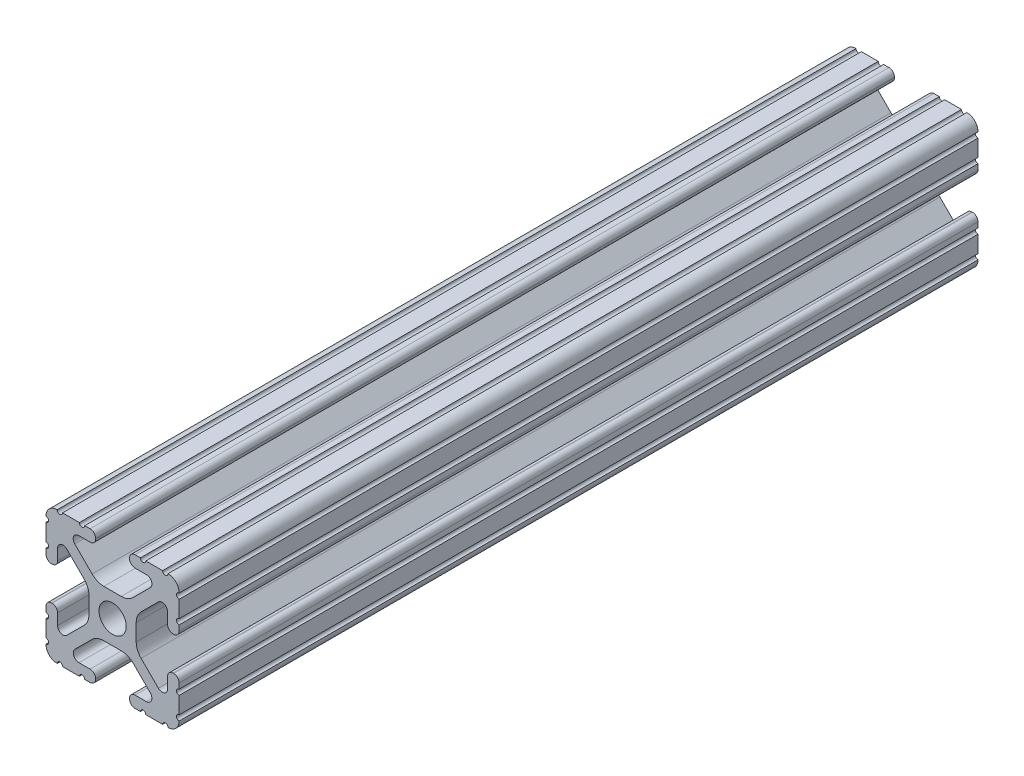
from build123d import *

# Parameters (mm, degrees)
SKETCH1_R           = 2.6035
BOSS_EXTRUDE1_DEPTH = 304.8
SKETCH2_R           = 37.713648337
CUT_EXTRUDE1_DEPTH  = 203.2
SKETCH4_R           = 34.529117014
CUT_EXTRUDE3_DEPTH  = 254
SKETCH5_R           = 0.254
CUT_EXTRUDE4_DEPTH  = 254


with BuildPart() as part:
    # Sketch1 → Boss-Extrude1 (new, symmetric)
    with BuildSketch(Plane.XY):
        with BuildLine():
            Line((-7.179650497, -8.645192506), (-3.952270251, -5.423690499))
            ThreePointArc((-3.952270251, -5.423690499), (-2.922936451, -4.736929036), (-1.709253557, -4.4958))
            Line((-1.709253557, -4.4958), (1.709253557, -4.4958))
            ThreePointArc((1.709253557, -4.4958), (2.922936451, -4.736929036), (3.952270251, -5.423690499))
            Line((3.952270251, -5.423690499), (7.179650497, -8.645192506))
            ThreePointArc((7.179650497, -8.645192506), (7.41473083, -9.822813117), (6.416408329, -10.4902))
            Line((6.416408329, -10.4902), (4.287512407, -10.4902))
            ThreePointArc((4.287512407, -10.4902), (3.54574862, -10.79744862), (3.2385, -11.539212407))
            Line((3.2385, -11.539212407), (3.2385, -11.650987593))
            ThreePointArc((3.2385, -11.650987593), (3.54574862, -12.39275138), (4.287512407, -12.7))
            Line((4.287512407, -12.7), (5.317126718, -12.7))
            ThreePointArc((5.317126718, -12.7), (5.825126718, -12.192), (6.333126718, -12.7))
            Line((6.333126718, -12.7), (9.550443118, -12.7))
            ThreePointArc((9.550443118, -12.7), (10.058366869, -12.192000006), (10.566443095, -12.699847501))
            ThreePointArc((10.566443095, -12.699847501), (12.082537762, -12.08250727), (12.699846982, -10.566399977))
            ThreePointArc((12.699846982, -10.566399977), (12.192000006, -10.058323491), (12.7, -9.5504))
            Line((12.7, -9.5504), (12.7, -6.3330836))
            ThreePointArc((12.7, -6.3330836), (12.192, -5.8250836), (12.7, -5.3170836))
            Line((12.7, -5.3170836), (12.7, -4.287469289))
            ThreePointArc((12.7, -4.287469289), (12.39275138, -3.545705502), (11.650987593, -3.238456882))
            Line((11.650987593, -3.238456882), (11.539212407, -3.238456882))
            ThreePointArc((11.539212407, -3.238456882), (10.79744862, -3.545705502), (10.4902, -4.287469289))
            Line((10.4902, -4.287469289), (10.4902, -6.402089023))
            ThreePointArc((10.4902, -6.402089023), (9.856505071, -7.351067942), (8.737131347, -7.129408934))
            Line((8.737131347, -7.129408934), (5.441005833, -3.840816462))
            ThreePointArc((5.441005833, -3.840816462), (4.750877967, -2.809883091), (4.5085, -1.593185507))
            Line((4.5085, -1.593185507), (4.5085, 1.593185507))
            ThreePointArc((4.5085, 1.593185507), (4.750877967, 2.809883091), (5.441005833, 3.840816462))
            Line((5.441005833, 3.840816462), (8.737131347, 7.129408934))
            ThreePointArc((8.737131347, 7.129408934), (9.856505071, 7.351067942), (10.4902, 6.402089023))
            Line((10.4902, 6.402089023), (10.4902, 4.287469289))
            ThreePointArc((10.4902, 4.287469289), (10.79744862, 3.545705502), (11.539212407, 3.238456882))
            Line((11.539212407, 3.238456882), (11.650987593, 3.238456882))
            ThreePointArc((11.650987593, 3.238456882), (12.39275138, 3.545705502), (12.7, 4.287469289))
            Line((12.7, 4.287469289), (12.7, 5.3170836))
            ThreePointArc((12.7, 5.3170836), (12.192, 5.8250836), (12.7, 6.3330836))
            Line((12.7, 6.3330836), (12.7, 9.5504))
            ThreePointArc((12.7, 9.5504), (12.192000006, 10.058323491), (12.699846982, 10.566399977))
            ThreePointArc((12.699846982, 10.566399977), (12.082537762, 12.08250727), (10.566443095, 12.699847501))
            ThreePointArc((10.566443095, 12.699847501), (10.058366869, 12.192000006), (9.550443118, 12.7))
            Line((9.550443118, 12.7), (6.333126718, 12.7))
            ThreePointArc((6.333126718, 12.7), (5.825126718, 12.192), (5.317126718, 12.7))
            Line((5.317126718, 12.7), (4.287512407, 12.7))
            ThreePointArc((4.287512407, 12.7), (3.54574862, 12.39275138), (3.2385, 11.650987593))
            Line((3.2385, 11.650987593), (3.2385, 11.539212407))
            ThreePointArc((3.2385, 11.539212407), (3.54574862, 10.79744862), (4.287512407, 10.4902))
            Line((4.287512407, 10.4902), (6.476788598, 10.4902))
            ThreePointArc((6.476788598, 10.4902), (7.432222385, 9.85140422), (7.207036008, 8.724370562))
            Line((7.207036008, 8.724370562), (3.898272566, 5.423169045))
            ThreePointArc((3.898272566, 5.423169045), (2.869120213, 4.736787962), (1.655778399, 4.4958))
            Line((1.655778399, 4.4958), (-1.655778399, 4.4958))
            ThreePointArc((-1.655778399, 4.4958), (-2.869120213, 4.736787962), (-3.898272566, 5.423169045))
            Line((-3.898272566, 5.423169045), (-7.207036008, 8.724370562))
            ThreePointArc((-7.207036008, 8.724370562), (-7.432222385, 9.85140422), (-6.476788598, 10.4902))
            Line((-6.476788598, 10.4902), (-4.287512407, 10.4902))
            ThreePointArc((-4.287512407, 10.4902), (-3.54574862, 10.79744862), (-3.2385, 11.539212407))
            Line((-3.2385, 11.539212407), (-3.2385, 11.650987593))
            ThreePointArc((-3.2385, 11.650987593), (-3.54574862, 12.39275138), (-4.287512407, 12.7))
            Line((-4.287512407, 12.7), (-5.317126718, 12.7))
            ThreePointArc((-5.317126718, 12.7), (-5.825126718, 12.192), (-6.333126718, 12.7))
            Line((-6.333126718, 12.7), (-9.550443118, 12.7))
            ThreePointArc((-9.550443118, 12.7), (-10.058366869, 12.192000006), (-10.566443095, 12.699847501))
            ThreePointArc((-10.566443095, 12.699847501), (-12.082537762, 12.08250727), (-12.699846982, 10.566399977))
            ThreePointArc((-12.699846982, 10.566399977), (-12.192000006, 10.058323491), (-12.7, 9.5504))
            Line((-12.7, 9.5504), (-12.7, 6.3330836))
            ThreePointArc((-12.7, 6.3330836), (-12.192, 5.8250836), (-12.7, 5.3170836))
            Line((-12.7, 5.3170836), (-12.7, 4.287469289))
            ThreePointArc((-12.7, 4.287469289), (-12.39275138, 3.545705502), (-11.650987593, 3.238456882))
            Line((-11.650987593, 3.238456882), (-11.539212407, 3.238456882))
            ThreePointArc((-11.539212407, 3.238456882), (-10.79744862, 3.545705502), (-10.4902, 4.287469289))
            Line((-10.4902, 4.287469289), (-10.4902, 6.402089023))
            ThreePointArc((-10.4902, 6.402089023), (-9.856505071, 7.351067942), (-8.737131347, 7.129408934))
            Line((-8.737131347, 7.129408934), (-5.441005833, 3.840816462))
            ThreePointArc((-5.441005833, 3.840816462), (-4.750877967, 2.809883091), (-4.5085, 1.593185507))
            Line((-4.5085, 1.593185507), (-4.5085, -1.593185507))
            ThreePointArc((-4.5085, -1.593185507), (-4.750877967, -2.809883091), (-5.441005833, -3.840816462))
            Line((-5.441005833, -3.840816462), (-8.737131347, -7.129408934))
            ThreePointArc((-8.737131347, -7.129408934), (-9.856505071, -7.351067942), (-10.4902, -6.402089023))
            Line((-10.4902, -6.402089023), (-10.4902, -4.287469289))
            ThreePointArc((-10.4902, -4.287469289), (-10.79744862, -3.545705502), (-11.539212407, -3.238456882))
            Line((-11.539212407, -3.238456882), (-11.650987593, -3.238456882))
            ThreePointArc((-11.650987593, -3.238456882), (-12.39275138, -3.545705502), (-12.7, -4.287469289))
            Line((-12.7, -4.287469289), (-12.7, -5.3170836))
            ThreePointArc((-12.7, -5.3170836), (-12.192, -5.8250836), (-12.7, -6.3330836))
            Line((-12.7, -6.3330836), (-12.7, -9.5504))
            ThreePointArc((-12.7, -9.5504), (-12.192000006, -10.058323491), (-12.699846982, -10.566399977))
            ThreePointArc((-12.699846982, -10.566399977), (-12.082537762, -12.08250727), (-10.566443095, -12.699847501))
            ThreePointArc((-10.566443095, -12.699847501), (-10.058366869, -12.192000006), (-9.550443118, -12.7))
            Line((-9.550443118, -12.7), (-6.333126718, -12.7))
            ThreePointArc((-6.333126718, -12.7), (-5.825126718, -12.192), (-5.317126718, -12.7))
            Line((-5.317126718, -12.7), (-4.287512407, -12.7))
            ThreePointArc((-4.287512407, -12.7), (-3.54574862, -12.39275138), (-3.2385, -11.650987593))
            Line((-3.2385, -11.650987593), (-3.2385, -11.539212407))
            ThreePointArc((-3.2385, -11.539212407), (-3.54574862, -10.79744862), (-4.287512407, -10.4902))
            Line((-4.287512407, -10.4902), (-6.416408329, -10.4902))
            ThreePointArc((-6.416408329, -10.4902), (-7.41473083, -9.822813117), (-7.179650497, -8.645192506))
        make_face()
        Circle(SKETCH1_R, mode=Mode.SUBTRACT)
    extrude(amount=BOSS_EXTRUDE1_DEPTH, both=True)

    # Sketch2 → Cut-Extrude1 (cut)
    with BuildSketch(Plane.XY.offset(304.8)):
        Circle(SKETCH2_R)
    extrude(amount=-CUT_EXTRUDE1_DEPTH, mode=Mode.SUBTRACT)

    # Sketch4 → Cut-Extrude3 (cut)
    with BuildSketch(Plane.XY.offset(101.6)):
        Circle(SKETCH4_R)
    extrude(amount=-CUT_EXTRUDE3_DEPTH, mode=Mode.SUBTRACT)

    # Sketch5 → Cut-Extrude4 (cut)
    with BuildSketch(Plane(origin=(4.5085, 0, 0), x_dir=(0, 0, -1), z_dir=(1, 0, 0))):
        with Locations((228.6, 0)):
            Circle(SKETCH5_R)
    extrude(amount=-CUT_EXTRUDE4_DEPTH, mode=Mode.SUBTRACT)


solid = part.part
